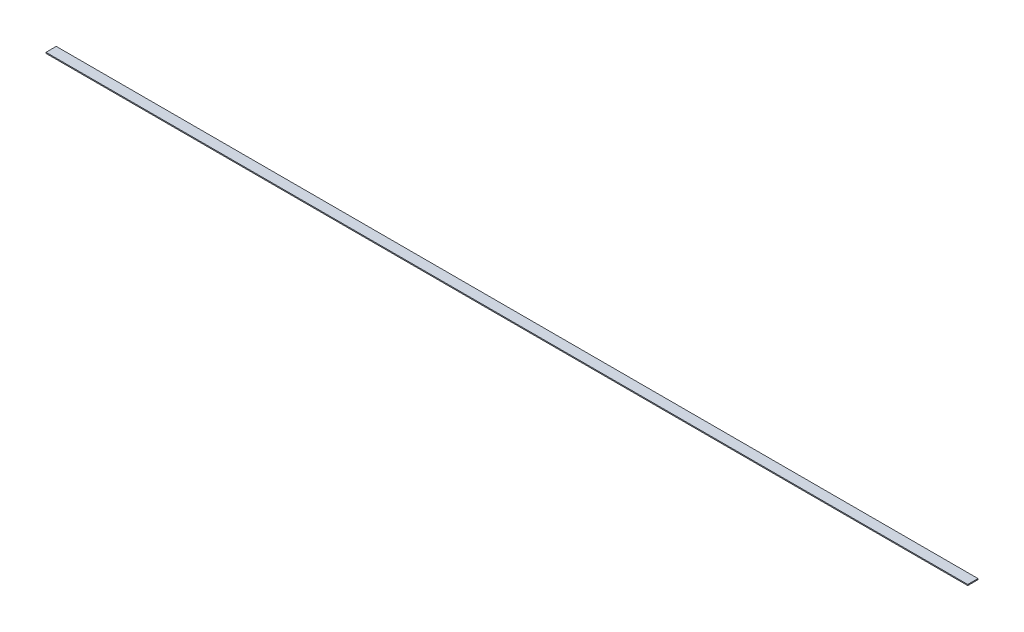
from build123d import *

# Parameters (mm, degrees)
SKETCH1_W           = 450
SKETCH1_H           = 5
BOSS_EXTRUDE1_DEPTH = 0.5


with BuildPart() as part:
    # Sketch1 → Boss-Extrude1 (new body)
    with BuildSketch(Plane(origin=(0, 0, 0), x_dir=(1, 0, 0), z_dir=(0, 1, 0))):
        with Locations((209.74916388, 3.879598662)):
            Rectangle(SKETCH1_W, SKETCH1_H)
    extrude(amount=BOSS_EXTRUDE1_DEPTH)


solid = part.part
